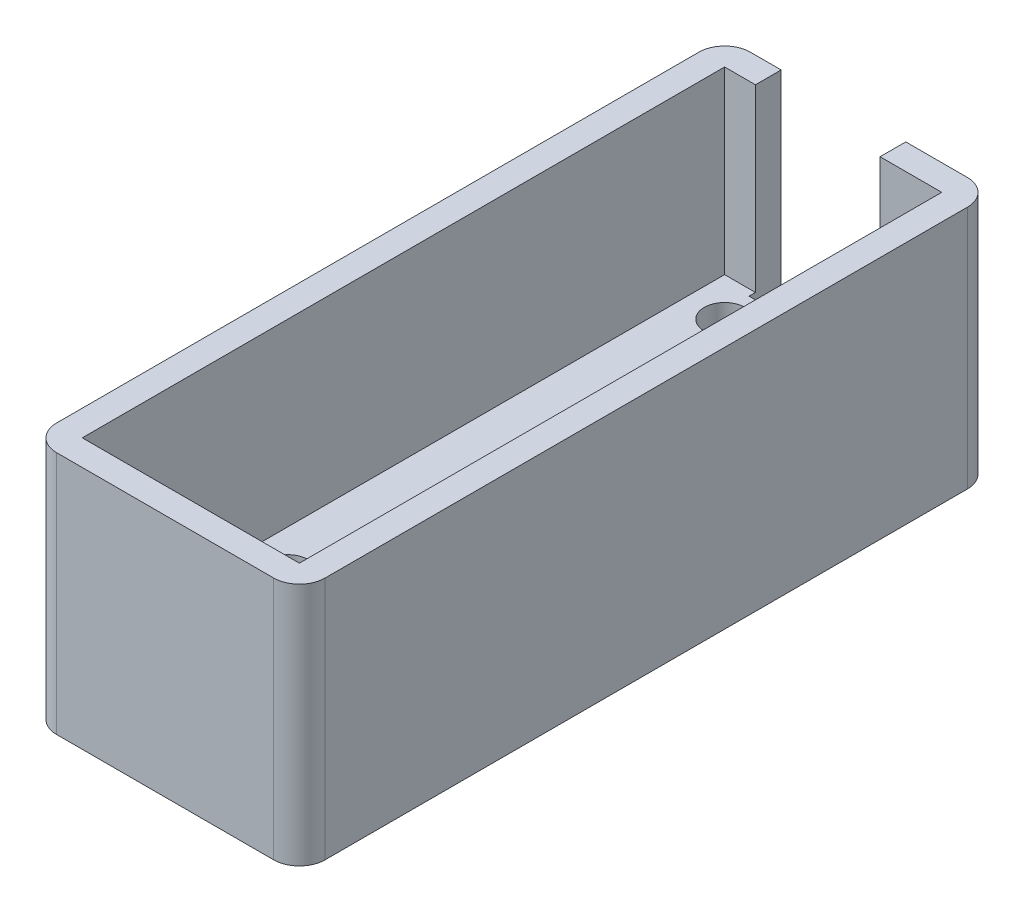
from build123d import *

# Parameters (mm, degrees)
SKETCH1_W                  = 26.543
SKETCH1_H                  = 68.58
SKETCH1_W_2                = 21.463
SKETCH1_H_2                = 63.5
BOSS_EXTRUDE1_DEPTH        = 17.78
SKETCH1_4_W                = 26.543
SKETCH1_4_H                = 68.58
BOSS_EXTRUDE2_DEPTH        = 6.35
SKETCH2_W                  = 12.319
SKETCH2_H                  = 18.415
CUT_EXTRUDE1_DEPTH         = 3.175
SKETCH3_W                  = 21.463
SKETCH3_H                  = 12.7
BOSS_EXTRUDE3_DEPTH        = 5.08
SKETCH4_R                  = 2.1336
CUT_EXTRUDE2_DEPTH         = 72.405291183
FILLET1_R                  = 2.54
F_10_32_TAPPED_HOLE1_D     = 4.0386
F_10_32_TAPPED_HOLE1_DEPTH = 12.0396
F_10_32_TAPPED_HOLE1_TIP   = 1.213317848


with BuildPart() as part:
    # Sketch1 → Boss-Extrude1 (new body)
    with BuildSketch(Plane(origin=(0, 0, 0), x_dir=(1, 0, 0), z_dir=(0, 1, 0))):
        with Locations((10.7315, 31.75)):
            Rectangle(SKETCH1_W, SKETCH1_H)
        with Locations((10.7315, 31.75)):
            Rectangle(SKETCH1_W_2, SKETCH1_H_2, mode=Mode.SUBTRACT)
    extrude(amount=BOSS_EXTRUDE1_DEPTH)

    # Sketch1_4 → Boss-Extrude2 (add)
    with BuildSketch(Plane(origin=(0, 0, 0), x_dir=(1, 0, 0), z_dir=(0, 1, 0))):
        with Locations((10.7315, 31.75)):
            Rectangle(SKETCH1_4_W, SKETCH1_4_H)
    extrude(amount=-BOSS_EXTRUDE2_DEPTH)

    # Sketch2 → Cut-Extrude1 (cut)
    with BuildSketch(Plane(origin=(0, 0, -66.04), x_dir=(-1, 0, 0), z_dir=(0, 0, -1))):
        with Locations((-9.2075, 8.5725)):
            Rectangle(SKETCH2_W, SKETCH2_H)
    extrude(amount=-CUT_EXTRUDE1_DEPTH, mode=Mode.SUBTRACT)

    # Sketch3 → Boss-Extrude3 (add)
    with BuildSketch(Plane(origin=(0, 0, 0), x_dir=(1, 0, 0), z_dir=(0, 1, 0))):
        with Locations((10.7315, 6.35)):
            Rectangle(SKETCH3_W, SKETCH3_H)
    extrude(amount=BOSS_EXTRUDE3_DEPTH)

    # Sketch4 → Cut-Extrude2 (cut, through all)
    with BuildSketch(Plane(origin=(0, 5.08, 0), x_dir=(1, 0, 0), z_dir=(0, 1, 0))):
        with Locations((9.2315, 4.447556381)):
            Circle(SKETCH4_R)
    extrude(amount=-CUT_EXTRUDE2_DEPTH, mode=Mode.SUBTRACT)

    # Fillet1
    fillet1_edges = [part.edges().sort_by_distance(p)[0] for p in [
        (24.003, 5.715, -66.04),
        (24.003, 5.715, 2.54),
        (-2.54, 5.715, 2.54),
        (-2.54, 5.715, -66.04),
        (10.7315, 5.08, -12.7),
    ]]
    fillet(fillet1_edges, radius=FILLET1_R)

    # 10-32 Tapped Hole1
    with Locations(Plane(origin=(0, 0, 0), x_dir=(1, 0, 0), z_dir=(0, 1, 0))):
        with Locations((3.81, 16.51), (17.653, 16.51), (17.653, 59.69), (3.81, 59.69)):
            Hole(F_10_32_TAPPED_HOLE1_D / 2, depth=F_10_32_TAPPED_HOLE1_DEPTH)
            with Locations((0, 0, -(F_10_32_TAPPED_HOLE1_DEPTH + F_10_32_TAPPED_HOLE1_TIP / 2))):  # 118° drill point
                Cone(0, F_10_32_TAPPED_HOLE1_D / 2, F_10_32_TAPPED_HOLE1_TIP, mode=Mode.SUBTRACT)


solid = part.part
